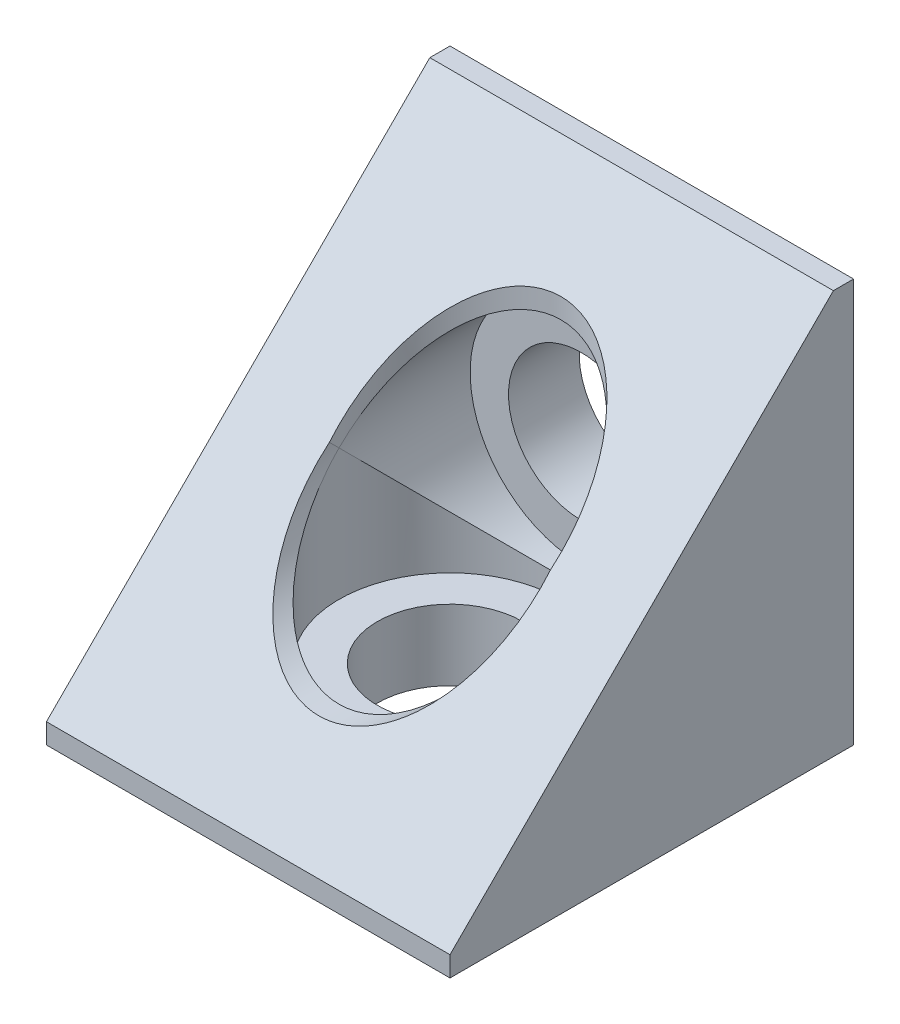
from build123d import *

# Parameters (mm, degrees)
BOSS_EXTRUDE1_DEPTH = 20
HOLE1_D             = 7.2
HOLE1_DEPTH         = 16.5
HOLE1_CBORE_D       = 11
HOLE1_CBORE_DEPTH   = 13


with BuildPart() as part:
    # Sketch1 → Boss-Extrude1 (new body)
    with BuildSketch(Plane(origin=(-10, 0, 0), x_dir=(0, -1, 0), z_dir=(-1, 0, 0))):
        Polygon((9, 10), (-10, -9), (-10, -10), (10, -10), (10, 10), align=None)
    extrude(amount=-BOSS_EXTRUDE1_DEPTH)

    # Sketch2 → Cut-Revolve1 (revolve, cut)
    with BuildSketch(Plane(origin=(0, 0, 0), x_dir=(0, 0, -1), z_dir=(1, 0, 0))):
        Polygon((5.5, 6.5), (0, 6.5), (0, -10), (3.6, -10), (3.6, -6.5), (5.5, -6.5), align=None)
    revolve(axis=Axis((0, 6.5, 0), (0, -1, 0)), mode=Mode.SUBTRACT)

    # Hole1
    with Locations(Plane.XY.offset(6.5)):
        with Locations((0, 0)):
            CounterBoreHole(HOLE1_D / 2, HOLE1_CBORE_D / 2, HOLE1_CBORE_DEPTH, depth=HOLE1_DEPTH)


solid = part.part
